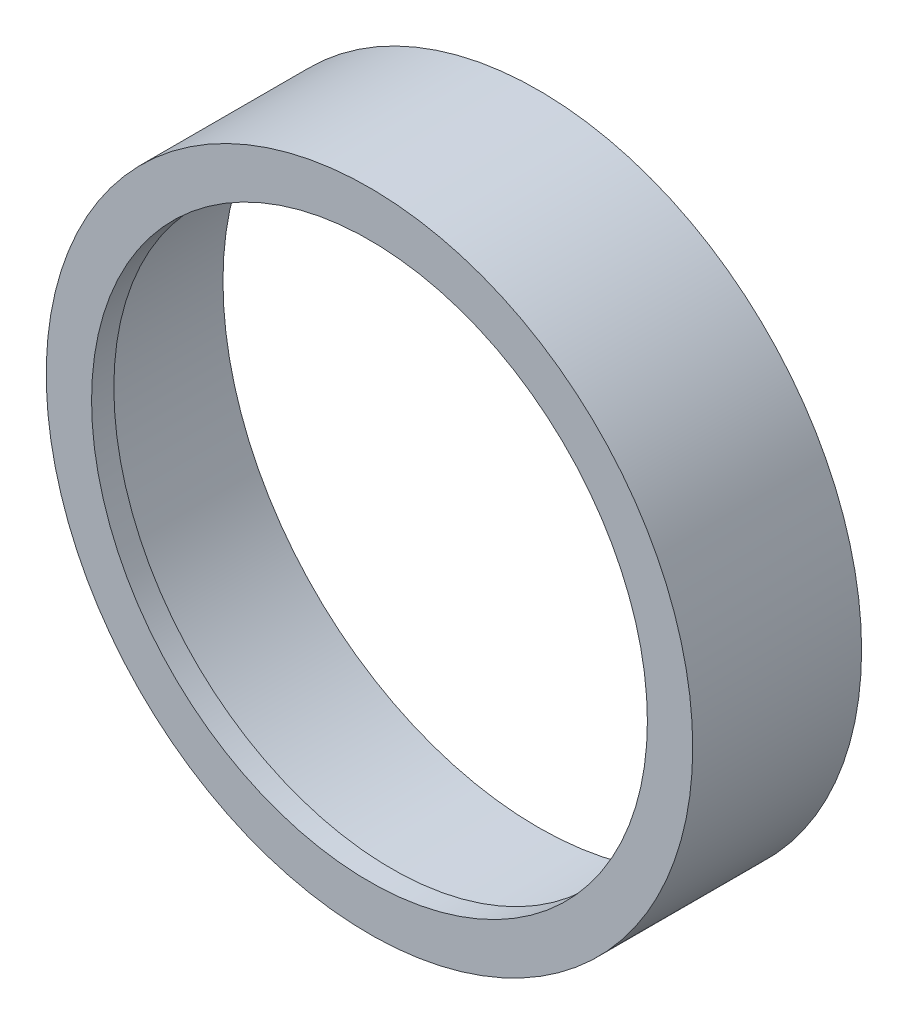
from build123d import *

# Parameters (mm, degrees)
SKETCH1_R           = 24.81
BOSS_EXTRUDE1_DEPTH = 12.96
SKETCH3_R           = 24.205
CUT_EXTRUDE2_DEPTH  = 11.25
SKETCH4_R           = 21.33
CUT_EXTRUDE3_DEPTH  = 11.25


with BuildPart() as part:
    # Sketch1 → Boss-Extrude1 (new body)
    with BuildSketch(Plane.XY):
        Circle(SKETCH1_R)
    extrude(amount=BOSS_EXTRUDE1_DEPTH)

    # Sketch3 → Cut-Extrude2 (cut)
    with BuildSketch(Plane(origin=(0, 0, 0), x_dir=(-1, 0, 0), z_dir=(0, 0, -1))):
        Circle(SKETCH3_R)
    extrude(amount=-CUT_EXTRUDE2_DEPTH, mode=Mode.SUBTRACT)

    # Sketch4 → Cut-Extrude3 (cut)
    with BuildSketch(Plane.XY.offset(12.96)):
        Circle(SKETCH4_R)
    extrude(amount=-CUT_EXTRUDE3_DEPTH, mode=Mode.SUBTRACT)


solid = part.part
